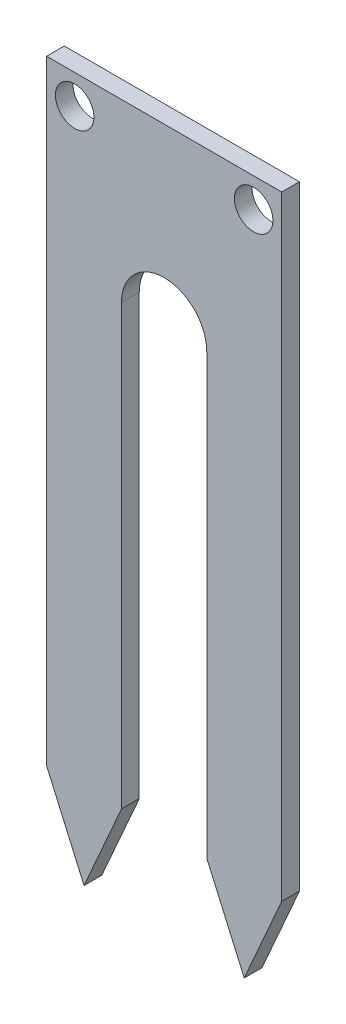
from build123d import *

# Parameters (mm, degrees)
BOSS_EXTRU_1_DEPTH      = 1.53
ESQUISSE2_R             = 1.665
ENL_V_MAT_EXTRU_1_DEPTH = 1.53


with BuildPart() as part:
    # Esquisse1 → Boss.-Extru.1 (new body)
    with BuildSketch(Plane.XY):
        with BuildLine():
            Line((0, 7.35), (0, 60.41))
            Line((0, 60.41), (20.31, 60.41))
            Line((20.31, 60.41), (20.31, 7.35))
            Line((20.31, 7.35), (17.0725, 0))
            Line((17.0725, 0), (13.835, 7.35))
            Line((13.835, 7.35), (13.835, 45.25))
            ThreePointArc((13.835, 45.25), (10.155, 48.93), (6.475, 45.25))
            Line((6.475, 45.25), (6.475, 7.35))
            Line((6.475, 7.35), (3.2375, 0))
            Line((3.2375, 0), (0, 7.35))
        make_face()
    extrude(amount=BOSS_EXTRU_1_DEPTH)

    # Esquisse2 → Enlèv. mat.-Extru.1 (cut)
    with BuildSketch(Plane.XY.offset(1.53)):
        with Locations((2.425, 57.885)):
            Circle(ESQUISSE2_R)
        with Locations((17.885, 57.885)):
            Circle(ESQUISSE2_R)
    extrude(amount=-ENL_V_MAT_EXTRU_1_DEPTH, mode=Mode.SUBTRACT)


solid = part.part
